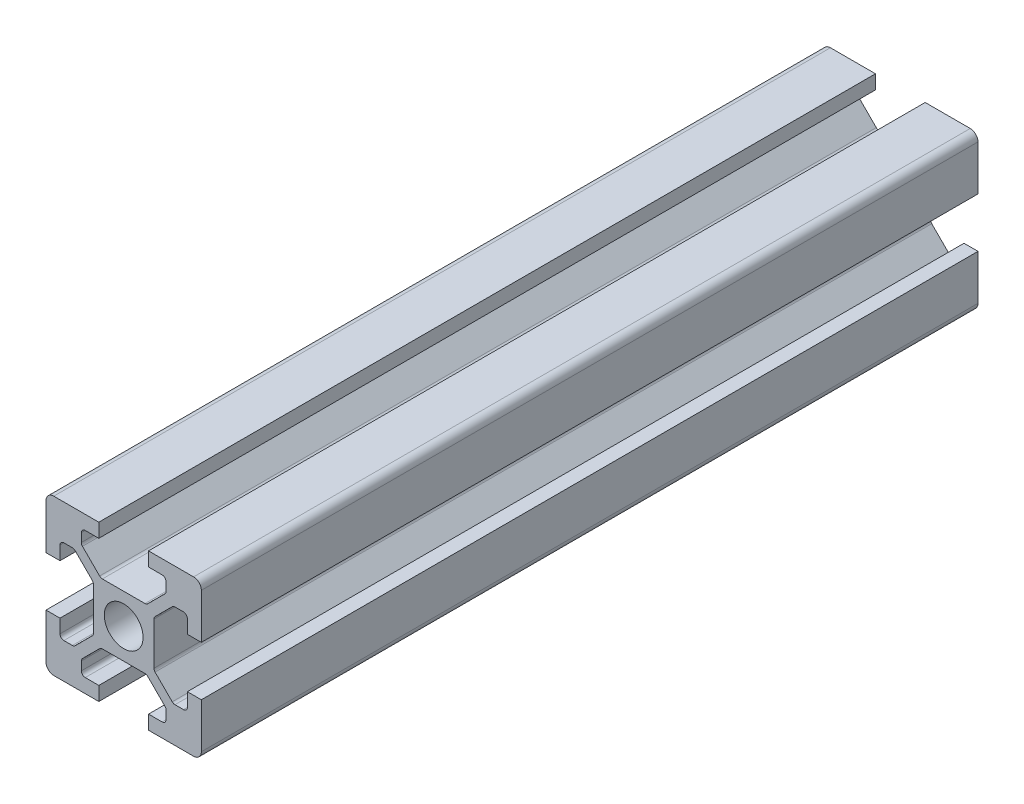
from build123d import *

# Parameters (mm, degrees)
SKETCH1_R           = 2.5
BOSS_EXTRUDE1_DEPTH = 300
FILLET1_R           = 1
FILLET2_R           = 0.5
FILLET3_R           = 0.5
FILLET4_R           = 0.5
FILLET5_R           = 0.5
SKETCH4_W           = 85.130466005
SKETCH4_H           = 76.492403511
CUT_EXTRUDE4_DEPTH  = 200


with BuildPart() as part:
    # Sketch1 → Boss-Extrude1 (new body)
    with BuildSketch(Plane.XY):
        Polygon((13.2, 0), (13.2, 1.8), (15.45, 1.8), (15.45, 3.6), (12.95, 6.1), (7.05, 6.1), (4.55, 3.6), (4.55, 1.8), (6.8, 1.8), (6.8, 0), (0, 0), (0, 6.8), (1.8, 6.8), (1.8, 4.55), (3.6, 4.55), (6.1, 7.05), (6.1, 12.95), (3.6, 15.45), (1.8, 15.45), (1.8, 13.2), (0, 13.2), (0, 20), (6.8, 20), (6.8, 18.2), (4.55, 18.2), (4.55, 16.4), (7.05, 13.9), (12.95, 13.9), (15.45, 16.4), (15.45, 18.2), (13.2, 18.2), (13.2, 20), (20, 20), (20, 13.2), (18.2, 13.2), (18.2, 15.45), (16.4, 15.45), (13.9, 12.95), (13.9, 7.05), (16.4, 4.55), (18.2, 4.55), (18.2, 6.8), (20, 6.8), (20, 0), align=None)
        with Locations((10, 10)):
            Circle(SKETCH1_R, mode=Mode.SUBTRACT)
    extrude(amount=BOSS_EXTRUDE1_DEPTH)

    # Fillet1
    fillet1_edges = [part.edges().sort_by_distance(p)[0] for p in [
        (0, 0, 150),
        (0, 20, 150),
        (20, 20, 150),
        (20, 0, 150),
    ]]
    fillet(fillet1_edges, radius=FILLET1_R)

    # Fillet2
    fillet2_edges = [part.edges().sort_by_distance(p)[0] for p in [
        (4.55, 18.2, 150),
        (4.55, 16.4, 150),
        (7.05, 13.9, 150),
        (12.95, 13.9, 150),
        (15.45, 16.4, 150),
        (15.45, 18.2, 150),
    ]]
    fillet(fillet2_edges, radius=FILLET2_R)

    # Fillet3
    fillet3_edges = [part.edges().sort_by_distance(p)[0] for p in [
        (18.2, 15.45, 150),
        (16.4, 15.45, 150),
        (13.9, 12.95, 150),
        (13.9, 7.05, 150),
        (16.4, 4.55, 150),
        (18.2, 4.55, 150),
    ]]
    fillet(fillet3_edges, radius=FILLET3_R)

    # Fillet4
    fillet4_edges = [part.edges().sort_by_distance(p)[0] for p in [
        (1.8, 4.55, 150),
        (3.6, 4.55, 150),
        (6.1, 7.05, 150),
        (6.1, 12.95, 150),
        (3.6, 15.45, 150),
        (1.8, 15.45, 150),
    ]]
    fillet(fillet4_edges, radius=FILLET4_R)

    # Fillet5
    fillet5_edges = [part.edges().sort_by_distance(p)[0] for p in [
        (15.45, 1.8, 150),
        (15.45, 3.6, 150),
        (12.95, 6.1, 150),
        (7.05, 6.1, 150),
        (4.55, 3.6, 150),
        (4.55, 1.8, 150),
    ]]
    fillet(fillet5_edges, radius=FILLET5_R)

    # Sketch4 → Cut-Extrude4 (cut)
    with BuildSketch(Plane(origin=(0, 0, 0), x_dir=(-1, 0, 0), z_dir=(0, 0, -1))):
        with Locations((13.179490335, -10.50880322)):
            Rectangle(SKETCH4_W, SKETCH4_H)
    extrude(amount=-CUT_EXTRUDE4_DEPTH, mode=Mode.SUBTRACT)


solid = part.part
